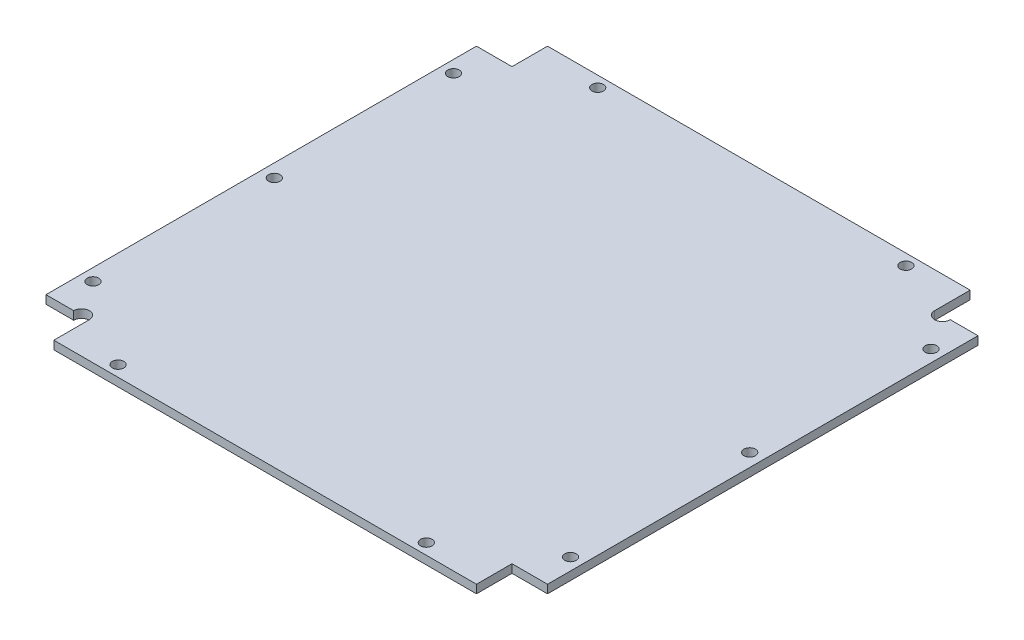
from build123d import *

# Parameters (mm, degrees)
BOSS_EXTRUDE1_DEPTH         = 1.6
HOLE_WIZARD_2_2_2_2_1_D     = 2.2
HOLE_WIZARD_2_2_2_2_1_DEPTH = 2
SKETCH12_R                  = 1.5
CUT_EXTRUDE1_DEPTH          = 2.6
HOLE_WIZARD_2_2_2_2_2_D     = 2.2
HOLE_WIZARD_2_2_2_2_2_DEPTH = 1.6


with BuildPart() as part:
    # Sketch1 → Boss-Extrude1 (new body)
    with BuildSketch(Plane(origin=(0, 0, 0), x_dir=(1, 0, 0), z_dir=(0, 1, 0))):
        Polygon((-35.644384454, 8.907074992), (-28.844384454, 8.907074992), (-28.844384454, 15.707074992), (52.055615546, 15.707074992), (52.055615546, 8.907074992), (60.355615546, 8.907074992), (60.355615546, -73.492925008), (53.555615546, -73.492925008), (53.555615546, -80.292925008), (-27.344384454, -80.292925008), (-27.344384454, -73.492925008), (-35.644384454, -73.492925008), align=None)
    extrude(amount=BOSS_EXTRUDE1_DEPTH)

    # Ø2.2 (2.2) 直径の穴1
    with Locations(Plane(origin=(0, 1.6, 0), x_dir=(1, 0, 0), z_dir=(0, 1, 0))):
        with Locations((57.855615546, -32.292925008), (-33.144384454, -32.292925008), (41.855615546, -78.192925008), (41.855615546, 13.607074992), (-17.144384454, 13.607074992), (-17.144384454, -78.192925008)):
            Hole(HOLE_WIZARD_2_2_2_2_1_D / 2, depth=HOLE_WIZARD_2_2_2_2_1_DEPTH)

    # Sketch12 → Cut-Extrude1 (cut, through all)
    with BuildSketch(Plane(origin=(0, 1.6, 0), x_dir=(1, 0, 0), z_dir=(0, 1, 0))):
        with Locations((53.555615546, 8.907074992)):
            Circle(SKETCH12_R)
        with Locations((-28.844384454, -73.492925008)):
            Circle(SKETCH12_R)
    extrude(amount=-CUT_EXTRUDE1_DEPTH, mode=Mode.SUBTRACT)

    # Ø2.2 (2.2) 直径の穴2
    with Locations(Plane(origin=(0, 1.6, 0), x_dir=(1, 0, 0), z_dir=(0, 1, 0))):
        with Locations((-33.344384454, 2.207074992), (-33.344384454, -66.792925008), (58.055615546, -66.792925008), (58.055615546, 2.207074992)):
            Hole(HOLE_WIZARD_2_2_2_2_2_D / 2, depth=HOLE_WIZARD_2_2_2_2_2_DEPTH)


solid = part.part
